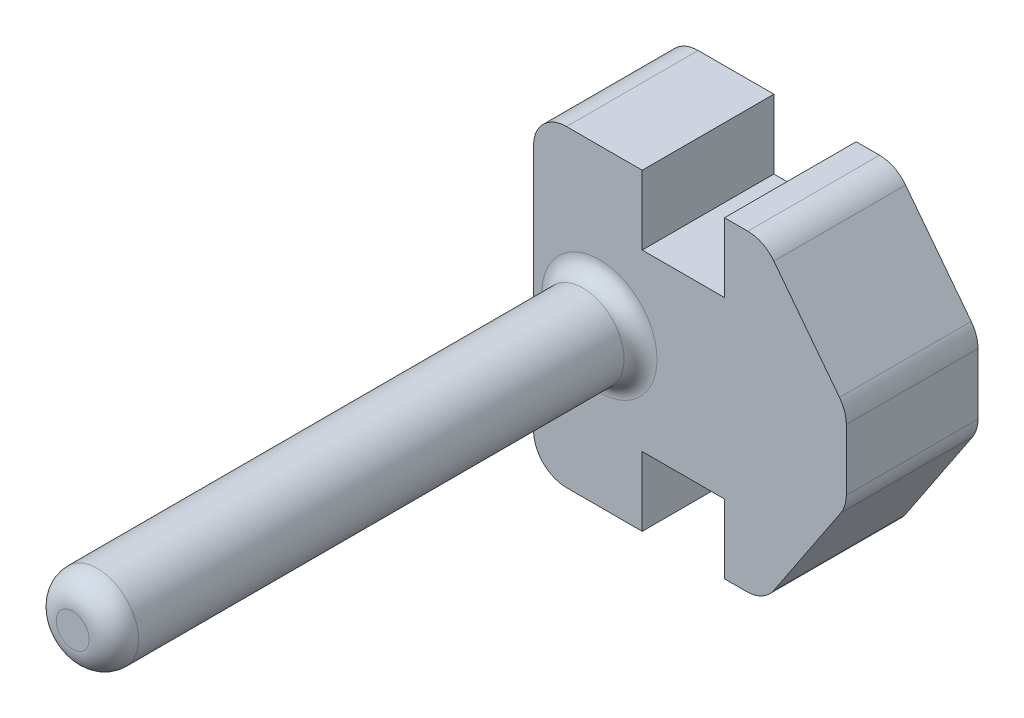
from build123d import *

# Parameters (mm, degrees)
BOSS_EXTRUDE1_DEPTH = 4
BOSS_EXTRUDE2_DEPTH = 4
SKETCH3_R           = 1.25
BOSS_EXTRUDE3_DEPTH = 16
FILLET1_R           = 1
FILLET2_R           = 0.5
FILLET3_R           = 0.75


with BuildPart() as part:
    # Sketch1 → Boss-Extrude1 (new body)
    with BuildSketch(Plane.XY):
        Polygon((2.3, -4.75), (3.5, -4.75), (3.5, 4.75), (2.3, 4.75), (2.3, 2.65), (-0.2, 2.65), (-0.2, 4.75), (-3.5, 4.75), (-3.5, -4.75), (-0.2, -4.75), (-0.2, -2.65), (2.3, -2.65), align=None)
    extrude(amount=BOSS_EXTRUDE1_DEPTH)

    # Sketch2 → Boss-Extrude2 (add)
    with BuildSketch(Plane(origin=(0, 0, 0), x_dir=(-1, 0, 0), z_dir=(0, 0, -1))):
        Polygon((-6, 1.5), (-6, -1), (-3.5, -4.75), (-3.5, 4.75), align=None)
    extrude(amount=-BOSS_EXTRUDE2_DEPTH)

    # Sketch3 → Boss-Extrude3 (add)
    with BuildSketch(Plane.XY.offset(4)):
        with Locations((-1.5, 0)):
            Circle(SKETCH3_R)
    extrude(amount=BOSS_EXTRUDE3_DEPTH)

    # Fillet1
    fillet1_edges = [part.edges().sort_by_distance(p)[0] for p in [
        (-3.5, -4.75, 2),
        (-3.5, 4.75, 2),
        (3.5, 4.75, 2),
        (3.5, -4.75, 2),
        (6, -1, 2),
        (6, 1.5, 2),
    ]]
    fillet(fillet1_edges, radius=FILLET1_R)

    # Fillet2
    fillet2_edges = [part.edges().sort_by_distance(p)[0] for p in [
        (-2.75, 0, 4),
    ]]
    fillet(fillet2_edges, radius=FILLET2_R)

    # Fillet3
    fillet3_edges = [part.edges().sort_by_distance(p)[0] for p in [
        (-2.75, 0, 20),
    ]]
    fillet(fillet3_edges, radius=FILLET3_R)


solid = part.part
